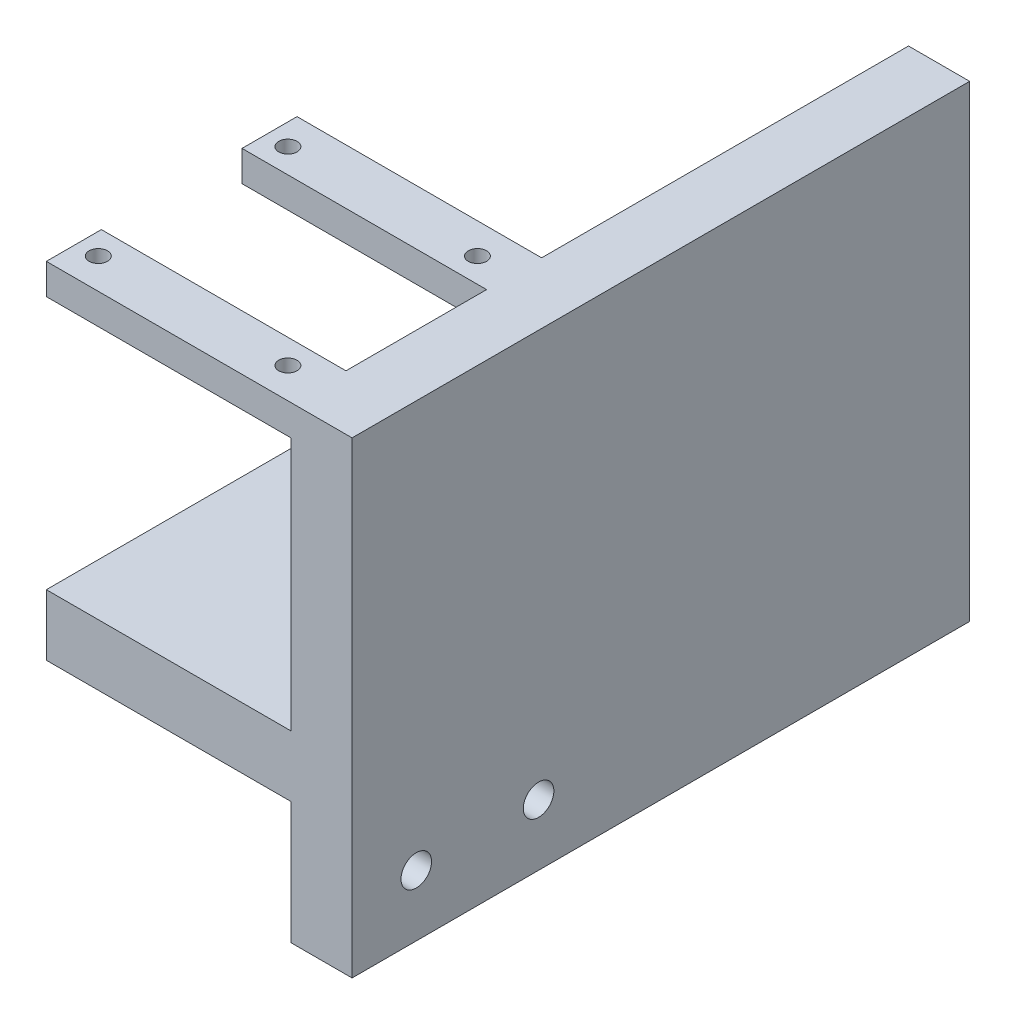
from build123d import *

# Parameters (mm, degrees)
SKETCH1_W           = 41
SKETCH1_H           = 56.5
SKETCH1_H_2         = 20
SKETCH1_R           = 2.5
BOSS_EXTRUDE1_DEPTH = 10
SKETCH3_W           = 40.5
SKETCH3_H           = 10
BOSS_EXTRUDE2_DEPTH = 40
SKETCH4_W           = 9
SKETCH4_H           = 5
BOSS_EXTRUDE3_DEPTH = 40
SKETCH5_R           = 1.5
CUT_EXTRUDE1_DEPTH  = 5
SKETCH6_W           = 10
SKETCH6_H           = 76.5
SKETCH6_W_2         = 40
SKETCH6_H_2         = 10
BOSS_EXTRUDE4_DEPTH = 60


with BuildPart() as part:
    # Sketch1 → Boss-Extrude1 (new body)
    with BuildSketch(Plane(origin=(0, 0, 0), x_dir=(0, 0, -1), z_dir=(1, 0, 0))):
        with Locations((0, 28.25)):
            Rectangle(SKETCH1_W, SKETCH1_H)
        with Locations((0, -10)):
            Rectangle(SKETCH1_W, SKETCH1_H_2)
        with Locations((10, -10)):
            Circle(SKETCH1_R, mode=Mode.SUBTRACT)
        with Locations((-10, -10)):
            Circle(SKETCH1_R, mode=Mode.SUBTRACT)
    extrude(amount=BOSS_EXTRUDE1_DEPTH)

    # Sketch3 → Boss-Extrude2 (add)
    with BuildSketch(Plane.ZY):
        with Locations((0.25, 5)):
            Rectangle(SKETCH3_W, SKETCH3_H)
    extrude(amount=BOSS_EXTRUDE2_DEPTH)

    # Sketch4 → Boss-Extrude3 (add)
    with BuildSketch(Plane.ZY):
        with Locations((-16, 54)):
            Rectangle(SKETCH4_W, SKETCH4_H)
    boss_extrude3 = extrude(amount=BOSS_EXTRUDE3_DEPTH)

    # Sketch5 → Cut-Extrude1 (cut)
    with BuildSketch(Plane(origin=(0, 56.5, 0), x_dir=(1, 0, 0), z_dir=(0, 1, 0))):
        with Locations((-36.5, 15.5)):
            Circle(SKETCH5_R)
        with Locations((-5.5, 15.5)):
            Circle(SKETCH5_R)
    cut_extrude1 = extrude(amount=-CUT_EXTRUDE1_DEPTH, mode=Mode.SUBTRACT)

    # Mirror2: Boss-Extrude3, Cut-Extrude1 across plane
    add(boss_extrude3.mirror(Plane.XY))
    add(cut_extrude1.mirror(Plane.XY), mode=Mode.SUBTRACT)

    # Sketch6 → Boss-Extrude4 (add)
    with BuildSketch(Plane(origin=(0, 0, -20.5), x_dir=(-1, 0, 0), z_dir=(0, 0, -1))):
        with Locations((-5, 18.25)):
            Rectangle(SKETCH6_W, SKETCH6_H)
        with Locations((20, 5)):
            Rectangle(SKETCH6_W_2, SKETCH6_H_2)
    extrude(amount=BOSS_EXTRUDE4_DEPTH)


solid = part.part
